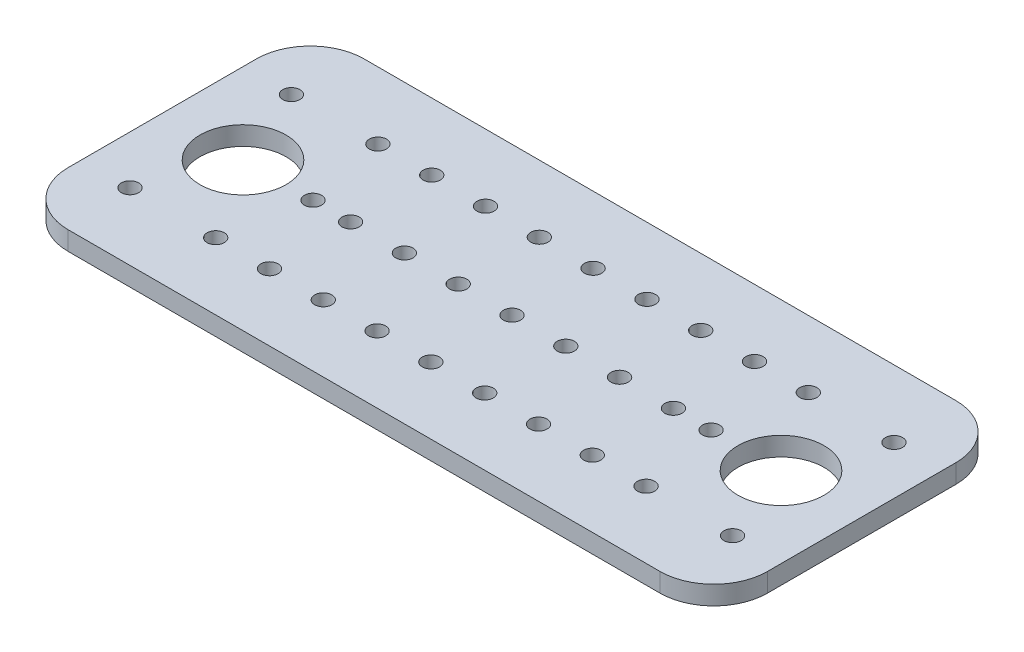
from build123d import *

# Parameters (mm, degrees)
SKETCH1_W           = 130
SKETCH1_H           = 55
SKETCH1_R           = 1.6
SKETCH1_R_2         = 8
BOSS_EXTRUDE4_DEPTH = 3.5
FILLET4_R           = 10


with BuildPart() as part:
    # Sketch1 → Boss-Extrude4 (new body)
    with BuildSketch(Plane(origin=(0, 0, 0), x_dir=(1, 0, 0), z_dir=(0, 1, 0))):
        with Locations((65, -27.5)):
            Rectangle(SKETCH1_W, SKETCH1_H)
        with Locations((9, -12.5)):
            Circle(SKETCH1_R, mode=Mode.SUBTRACT)
        with Locations((9, -42.5)):
            Circle(SKETCH1_R, mode=Mode.SUBTRACT)
        with Locations((121, -42.5)):
            Circle(SKETCH1_R, mode=Mode.SUBTRACT)
        with Locations((121, -12.5)):
            Circle(SKETCH1_R, mode=Mode.SUBTRACT)
        with Locations((15, -27.5)):
            Circle(SKETCH1_R_2, mode=Mode.SUBTRACT)
        with Locations((115, -27.5)):
            Circle(SKETCH1_R_2, mode=Mode.SUBTRACT)
        with Locations((65, -12.425)):
            Circle(SKETCH1_R, mode=Mode.SUBTRACT)
        with Locations((65, -42.575)):
            Circle(SKETCH1_R, mode=Mode.SUBTRACT)
        with Locations((75, -12.425)):
            Circle(SKETCH1_R, mode=Mode.SUBTRACT)
        with Locations((75, -42.575)):
            Circle(SKETCH1_R, mode=Mode.SUBTRACT)
        with Locations((85, -12.425)):
            Circle(SKETCH1_R, mode=Mode.SUBTRACT)
        with Locations((85, -42.575)):
            Circle(SKETCH1_R, mode=Mode.SUBTRACT)
        with Locations((95, -12.425)):
            Circle(SKETCH1_R, mode=Mode.SUBTRACT)
        with Locations((95, -42.575)):
            Circle(SKETCH1_R, mode=Mode.SUBTRACT)
        with Locations((105, -12.425)):
            Circle(SKETCH1_R, mode=Mode.SUBTRACT)
        with Locations((105, -42.575)):
            Circle(SKETCH1_R, mode=Mode.SUBTRACT)
        with Locations((55, -12.425)):
            Circle(SKETCH1_R, mode=Mode.SUBTRACT)
        with Locations((55, -42.575)):
            Circle(SKETCH1_R, mode=Mode.SUBTRACT)
        with Locations((45, -12.425)):
            Circle(SKETCH1_R, mode=Mode.SUBTRACT)
        with Locations((45, -42.575)):
            Circle(SKETCH1_R, mode=Mode.SUBTRACT)
        with Locations((35, -12.425)):
            Circle(SKETCH1_R, mode=Mode.SUBTRACT)
        with Locations((35, -42.575)):
            Circle(SKETCH1_R, mode=Mode.SUBTRACT)
        with Locations((25, -12.425)):
            Circle(SKETCH1_R, mode=Mode.SUBTRACT)
        with Locations((25, -42.575)):
            Circle(SKETCH1_R, mode=Mode.SUBTRACT)
        with Locations((65, -27.5)):
            Circle(SKETCH1_R, mode=Mode.SUBTRACT)
        with Locations((75, -27.5)):
            Circle(SKETCH1_R, mode=Mode.SUBTRACT)
        with Locations((85, -27.5)):
            Circle(SKETCH1_R, mode=Mode.SUBTRACT)
        with Locations((95, -27.5)):
            Circle(SKETCH1_R, mode=Mode.SUBTRACT)
        with Locations((55, -27.5)):
            Circle(SKETCH1_R, mode=Mode.SUBTRACT)
        with Locations((45, -27.5)):
            Circle(SKETCH1_R, mode=Mode.SUBTRACT)
        with Locations((35, -27.5)):
            Circle(SKETCH1_R, mode=Mode.SUBTRACT)
        with Locations((28, -27.5)):
            Circle(SKETCH1_R, mode=Mode.SUBTRACT)
        with Locations((102, -27.5)):
            Circle(SKETCH1_R, mode=Mode.SUBTRACT)
    extrude(amount=BOSS_EXTRUDE4_DEPTH)

    # Fillet4
    fillet4_edges = [part.edges().sort_by_distance(p)[0] for p in [
        (0, 1.75, 0),
        (130, 1.75, 0),
        (130, 1.75, 55),
        (0, 1.75, 55),
    ]]
    fillet(fillet4_edges, radius=FILLET4_R)


solid = part.part
